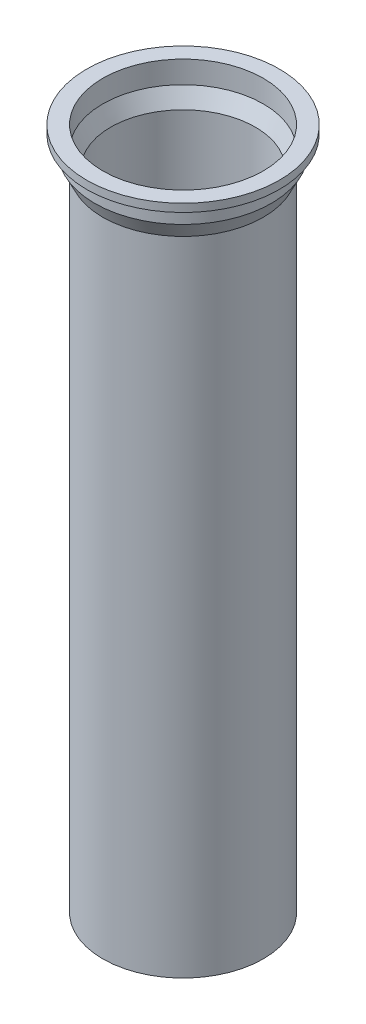
from build123d import *


with BuildPart() as part:
    # Croquis5 → Revolución1 (revolve)
    with BuildSketch(Plane.XY):
        Polygon((-60, 0), (-60, -5), (-55, -5), (-55, -15), (-50, -25), (-50, -425), (-45, -425), (-45, -23.819660113), (-50, -13.819660113), (-50, 0), align=None)
    revolve(axis=Axis((0, 0, 0), (0, -1, 0)))


solid = part.part
